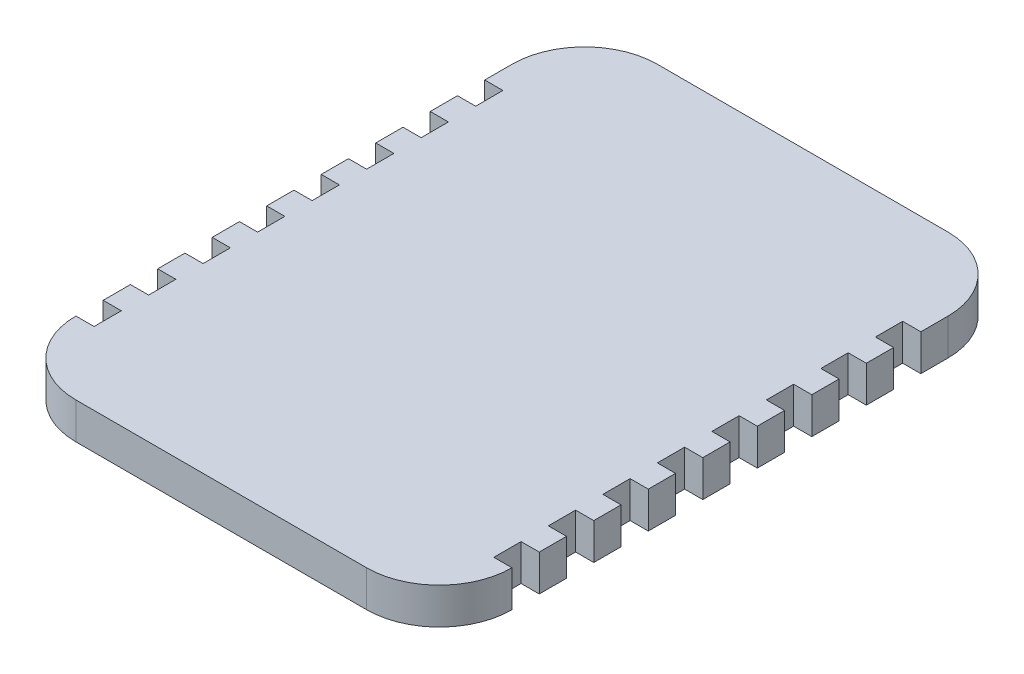
from build123d import *

# Parameters (mm, degrees)
BOSS_EXTRUDE1_DEPTH = 20
SKETCH3_W           = 15
SKETCH3_H           = 20
CUT_EXTRUDE1_DEPTH  = 10
SKETCH4_W           = 15
SKETCH4_H           = 20
CUT_EXTRUDE2_DEPTH  = 10


with BuildPart() as part:
    # Sketch1 → Boss-Extrude1 (new body)
    with BuildSketch(Plane(origin=(0, 0, 0), x_dir=(1, 0, 0), z_dir=(0, 1, 0))):
        with BuildLine():
            Line((-10, 30), (-10, 270))
            ThreePointArc((-10, 270), (1.715728753, 298.284271247), (30, 310))
            Line((30, 310), (190, 310))
            ThreePointArc((190, 310), (218.284271247, 298.284271247), (230, 270))
            Line((230, 270), (230, 30))
            ThreePointArc((230, 30), (218.284271247, 1.715728753), (190, -10))
            Line((190, -10), (30, -10))
            ThreePointArc((30, -10), (1.715728753, 1.715728753), (-10, 30))
        make_face()
    extrude(amount=BOSS_EXTRUDE1_DEPTH)

    # Sketch3 → Cut-Extrude1 (cut)
    with BuildSketch(Plane.ZY.offset(10)):
        with Locations((-247.5, 10)):
            Rectangle(SKETCH3_W, SKETCH3_H)
        with Locations((-217.5, 10)):
            Rectangle(SKETCH3_W, SKETCH3_H)
        with Locations((-187.5, 10)):
            Rectangle(SKETCH3_W, SKETCH3_H)
        with Locations((-157.5, 10)):
            Rectangle(SKETCH3_W, SKETCH3_H)
        with Locations((-127.5, 10)):
            Rectangle(SKETCH3_W, SKETCH3_H)
        with Locations((-97.5, 10)):
            Rectangle(SKETCH3_W, SKETCH3_H)
        with Locations((-67.5, 10)):
            Rectangle(SKETCH3_W, SKETCH3_H)
        with Locations((-37.5, 10)):
            Rectangle(SKETCH3_W, SKETCH3_H)
    extrude(amount=-CUT_EXTRUDE1_DEPTH, mode=Mode.SUBTRACT)

    # Sketch4 → Cut-Extrude2 (cut)
    with BuildSketch(Plane(origin=(230, 0, 0), x_dir=(0, 0, -1), z_dir=(1, 0, 0))):
        with Locations((247.5, 10)):
            Rectangle(SKETCH4_W, SKETCH4_H)
        with Locations((217.5, 10)):
            Rectangle(SKETCH4_W, SKETCH4_H)
        with Locations((157.5, 10)):
            Rectangle(SKETCH4_W, SKETCH4_H)
        with Locations((127.5, 10)):
            Rectangle(SKETCH4_W, SKETCH4_H)
        with Locations((97.5, 10)):
            Rectangle(SKETCH4_W, SKETCH4_H)
        with Locations((67.5, 10)):
            Rectangle(SKETCH4_W, SKETCH4_H)
        with Locations((37.5, 10)):
            Rectangle(SKETCH4_W, SKETCH4_H)
        with Locations((187.5, 10)):
            Rectangle(SKETCH4_W, SKETCH4_H)
    extrude(amount=-CUT_EXTRUDE2_DEPTH, mode=Mode.SUBTRACT)


solid = part.part
